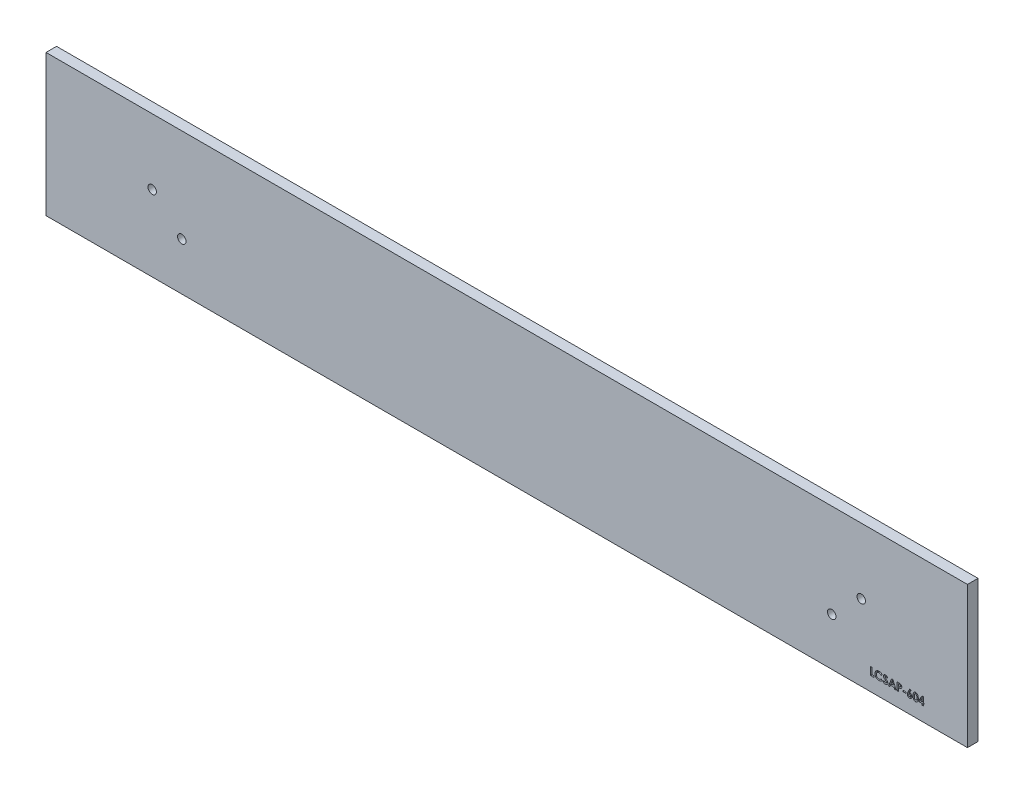
from build123d import *

# Parameters (mm, degrees)
SKETCH1_W           = 415.925
SKETCH1_H           = 63.8175
BOSS_EXTRUDE1_DEPTH = 4.7625
SKETCH2_R           = 1.905
CUT_EXTRUDE1_DEPTH  = 421.819391589
SKETCH3_W           = 1.211538462
SKETCH3_H           = 0.583333334
CUT_EXTRUDE2_DEPTH  = 1.016


with BuildPart() as part:
    # Sketch1 → Boss-Extrude1 (new body)
    with BuildSketch(Plane.XY):
        with Locations((207.9625, 31.90875)):
            Rectangle(SKETCH1_W, SKETCH1_H)
    extrude(amount=BOSS_EXTRUDE1_DEPTH)

    # Sketch2 → Cut-Extrude1 (cut, through all)
    with BuildSketch(Plane(origin=(0, 0, 0), x_dir=(-1, 0, 0), z_dir=(0, 0, -1))):
        with Locations((-367.9825, 34.2265)):
            Circle(SKETCH2_R)
        with Locations((-354.6475, 21.5265)):
            Circle(SKETCH2_R)
        with Locations((-47.9425, 34.2265)):
            Circle(SKETCH2_R)
        with Locations((-61.2775, 21.5265)):
            Circle(SKETCH2_R)
    extrude(amount=-CUT_EXTRUDE1_DEPTH, mode=Mode.SUBTRACT)

    # Sketch3 → Cut-Extrude2 (cut)
    # profile 1 of 9: a face of its own
    with BuildSketch(Plane.XY.offset(4.7625)):
        Polygon((395.456049679, 9.93974359), (396.110897436, 9.93974359), (396.110897436, 7.651282051), (396.425, 7.651282051), (396.425, 7.067948718), (396.110897436, 7.067948718), (396.110897436, 6.35), (395.482692308, 6.35), (395.482692308, 7.067948718), (394.001923077, 7.067948718), (394.001923077, 7.703866186), align=None)
        Polygon((395.482692308, 7.651282051), (395.482692308, 8.842487981), (394.707952724, 7.651282051), align=None, mode=Mode.SUBTRACT)
    # profile 2 of 9: a face of its own
    with BuildSketch(Plane.XY.offset(4.7625)):
        with BuildLine():
            add(Edge.make_bspline(
                [(392.533072917, 9.93974359), (392.563480652, 9.939292178), (392.623270385, 9.938404583), (392.711329406, 9.928791201), (392.796154591, 9.914268063), (392.878077785, 9.894013349), (392.956509297, 9.867206957), (393.032019968, 9.835120165), (393.103711003, 9.796069956), (393.172496691, 9.751960738), (393.238350535, 9.702022851), (393.299689786, 9.64509108), (393.357634627, 9.58247543), (393.410930767, 9.513229263), (393.460758465, 9.437982447), (393.506953994, 9.35672305), (393.549163718, 9.269053361), (393.587860706, 9.174815174), (393.622463675, 9.072595899), (393.651609713, 8.961223037), (393.676607317, 8.840671153), (393.697707059, 8.710640176), (393.713655053, 8.570957264), (393.724404323, 8.421715214), (393.73178098, 8.263201744), (393.732383012, 8.154462806), (393.732692308, 8.098597756)],
                knots=[0, 0, 0, 0, 0.879237366, 1.728815576, 2.559023295, 3.367336655, 4.166867292, 4.954216142, 5.737608147, 6.525189134, 7.316157332, 8.124696809, 8.942788509, 9.781158001, 10.649253743, 11.551476218, 12.482711956, 13.461909668, 14.496590415, 15.601789533, 16.789733467, 18.056700938, 19.410929216, 20.8549011, 22.384193279, 24, 24, 24, 24], degree=3))
            add(Edge.make_bspline(
                [(393.732692308, 8.098597756), (393.732358042, 8.042033772), (393.731708571, 7.932130965), (393.724710973, 7.77216765), (393.712660778, 7.621842014), (393.697129618, 7.481169608), (393.675856176, 7.350224719), (393.650942019, 7.228668289), (393.62133592, 7.116544378), (393.585593141, 7.014105625), (393.547130387, 6.919701935), (393.504805201, 6.832203181), (393.459355307, 6.751372369), (393.411823186, 6.675990055), (393.359602955, 6.608278471), (393.305236318, 6.545935071), (393.246356056, 6.491334593), (393.185441254, 6.441663175), (393.120260358, 6.398737102), (393.05148556, 6.361194666), (392.977890726, 6.330743291), (392.900817364, 6.304258312), (392.818951743, 6.285244955), (392.733594697, 6.27015848), (392.643782561, 6.261820769), (392.582634842, 6.260786421), (392.551302083, 6.26025641)],
                knots=[0, 0, 0, 0, 1.643780988, 3.193836972, 4.651895693, 6.025988579, 7.305620092, 8.505800249, 9.631074763, 10.672816429, 11.65661981, 12.592235626, 13.49536222, 14.350718032, 15.179365177, 15.97804903, 16.751647189, 17.51006938, 18.259804725, 19.016521909, 19.783502495, 20.571750527, 21.382245291, 22.22305063, 23.089471752, 24, 24, 24, 24], degree=3))
            add(Edge.make_bspline(
                [(392.551302083, 6.26025641), (392.51997017, 6.260796645), (392.458591414, 6.261854957), (392.368536417, 6.270096486), (392.282727022, 6.28530607), (392.200213712, 6.304404282), (392.121570768, 6.33068469), (392.0464211, 6.362047148), (391.975342543, 6.399355338), (391.908138292, 6.442381425), (391.845037802, 6.491720504), (391.78506049, 6.546844838), (391.728339031, 6.607614701), (391.675736299, 6.674710765), (391.626390812, 6.747237439), (391.580817167, 6.826022941), (391.539042751, 6.910952561), (391.499760854, 7.002144684), (391.465629858, 7.10156257), (391.435254856, 7.210094009), (391.410372454, 7.3286437), (391.39036036, 7.457173557), (391.374382717, 7.595411285), (391.362497186, 7.743423606), (391.35546072, 7.901279462), (391.354818059, 8.009781655), (391.354487179, 8.065645032)],
                knots=[0, 0, 0, 0, 0.917216111, 1.796812873, 2.643793957, 3.46689424, 4.273913431, 5.068098542, 5.848489301, 6.620921603, 7.401012384, 8.190319798, 9.003608147, 9.831726257, 10.68377682, 11.569763213, 12.493818149, 13.453288342, 14.474581811, 15.568529029, 16.750744269, 18.018426408, 19.375425659, 20.823733699, 22.36466933, 24, 24, 24, 24], degree=3))
            add(Edge.make_bspline(
                [(391.354487179, 8.065645032), (391.355086537, 8.143262797), (391.356243006, 8.293027275), (391.370898626, 8.509393402), (391.39240936, 8.709386406), (391.424003532, 8.892671749), (391.463069289, 9.059928265), (391.513095025, 9.210054156), (391.570045686, 9.345126752), (391.618574966, 9.425144571), (391.641947115, 9.463681891)],
                knots=[0, 0, 0, 0, 1.288568992, 2.486310467, 3.599230591, 4.627010532, 5.572937695, 6.447898582, 7.252493626, 8, 8, 8, 8], degree=3))
            add(Edge.make_bspline(
                [(391.641947115, 9.463681891), (391.669123137, 9.501540942), (391.722257615, 9.575562848), (391.815164735, 9.672739774), (391.914981339, 9.755850239), (392.023757603, 9.82301338), (392.139773185, 9.875978238), (392.264024139, 9.913386721), (392.396051626, 9.935182647), (392.486717103, 9.938200572), (392.533072917, 9.93974359)],
                knots=[0, 0, 0, 0, 1.058512271, 2.069600068, 3.047294572, 4.004278952, 4.967380941, 5.939006123, 6.946246673, 8, 8, 8, 8], degree=3))
        make_face()
        with BuildLine():
            add(Edge.make_bspline(
                [(392.548497596, 9.311538462), (392.521008751, 9.310235545), (392.467116023, 9.307681137), (392.388915106, 9.285997815), (392.315176524, 9.252506756), (392.259085555, 9.212205503), (392.217102022, 9.173571918), (392.187767826, 9.138609781), (392.159479618, 9.099594555), (392.134494048, 9.054765685), (392.110901148, 9.005733924), (392.087843773, 8.952276698), (392.06894278, 8.893080981), (392.050373055, 8.829154885), (392.034104244, 8.758731022), (392.020474546, 8.681233756), (392.00829761, 8.596159114), (391.999804052, 8.503451372), (391.991885506, 8.403207526), (391.986209118, 8.295204271), (391.983835962, 8.179470744), (391.983081608, 8.099766781), (391.982692308, 8.058633814)],
                knots=[0, 0, 0, 0, 1.076674018, 2.110852608, 3.161083442, 4.239746716, 4.804137807, 5.395870207, 6.026861976, 6.692161227, 7.405688833, 8.16177676, 8.973626916, 9.841385931, 10.773283133, 11.807421078, 12.927755683, 14.143907515, 15.458935494, 16.872852025, 18.386167141, 20, 20, 20, 20], degree=3))
            add(Edge.make_bspline(
                [(391.982692308, 8.058633814), (391.98333305, 8.005344067), (391.98456172, 7.903157026), (391.990996919, 7.756208503), (392.003895741, 7.622473515), (392.019939272, 7.501045689), (392.042473067, 7.392712518), (392.068399656, 7.29644907), (392.100416688, 7.21348247), (392.137418538, 7.142612834), (392.178399754, 7.082324181), (392.222886667, 7.031078555), (392.269364656, 6.986702261), (392.319284452, 6.950655944), (392.37252696, 6.923031708), (392.428647703, 6.903161936), (392.487682345, 6.890998822), (392.528108659, 6.889312189), (392.548497596, 6.888461538)],
                knots=[0, 0, 0, 0, 1.771748488, 3.397459088, 4.888034009, 6.237357457, 7.467047327, 8.564189669, 9.548206622, 10.417051504, 11.216568818, 11.965764335, 12.669334354, 13.348544111, 14.005342236, 14.656555988, 15.322436492, 16, 16, 16, 16], degree=3))
            add(Edge.make_bspline(
                [(392.548497596, 6.888461538), (392.56818685, 6.889043617), (392.606735959, 6.890183253), (392.662949195, 6.901881469), (392.716108425, 6.920900227), (392.766053145, 6.947803595), (392.812962, 6.982015344), (392.856605729, 7.023685815), (392.896655179, 7.073230366), (392.919988171, 7.109999749), (392.932011218, 7.128946314)],
                knots=[0, 0, 0, 0, 0.992283464, 1.942767638, 2.88273346, 3.832339453, 4.79467288, 5.803907806, 6.868395428, 8, 8, 8, 8], degree=3))
            add(Edge.make_bspline(
                [(392.932011218, 7.128946314), (392.946166331, 7.154836189), (392.975848455, 7.209125158), (393.010196661, 7.300735767), (393.039109066, 7.404057394), (393.06399355, 7.519411585), (393.081013019, 7.64725331), (393.095670165, 7.786771915), (393.102739671, 7.938669958), (393.103889565, 8.04390547), (393.104487179, 8.098597756)],
                knots=[0, 0, 0, 0, 0.710965849, 1.490837728, 2.352621235, 3.297892224, 4.334225155, 5.461620853, 6.680770821, 8, 8, 8, 8], degree=3))
            add(Edge.make_bspline(
                [(393.104487179, 8.098597756), (393.104256334, 8.153764798), (393.103811995, 8.259951935), (393.095659668, 8.412396063), (393.08430693, 8.551628473), (393.067701151, 8.677338316), (393.046334799, 8.789830761), (393.020000689, 8.889098454), (392.988954732, 8.975337033), (392.952137927, 9.048460505), (392.911361029, 9.110605426), (392.868075106, 9.163920947), (392.822097128, 9.209440394), (392.773503986, 9.247335064), (392.721170975, 9.276289435), (392.666097722, 9.296733616), (392.608171324, 9.309101659), (392.56865732, 9.310715231), (392.548497596, 9.311538462)],
                knots=[0, 0, 0, 0, 1.793836731, 3.452829483, 4.963243077, 6.335886805, 7.574563692, 8.684454726, 9.672768357, 10.54971625, 11.340229787, 12.085688095, 12.778991901, 13.440269426, 14.083255152, 14.715733572, 15.344777694, 16, 16, 16, 16], degree=3))
        make_face(mode=Mode.SUBTRACT)
    # profile 3 of 9: a face of its own
    with BuildSketch(Plane.XY.offset(4.7625)):
        with BuildLine():
            Line((389.904567308, 9.93974359), (390.460556891, 9.657892628))
            Line((390.460556891, 9.657892628), (389.850580929, 8.458974359))
            add(Edge.make_bspline(
                [(389.850580929, 8.458974359), (389.886617737, 8.458041348), (389.957598139, 8.456203629), (390.062031398, 8.441350882), (390.161871538, 8.415674043), (390.258125242, 8.381639463), (390.3496159, 8.335930683), (390.43781702, 8.281557705), (390.520446794, 8.21524401), (390.599399853, 8.141771954), (390.671191464, 8.060375475), (390.73355517, 7.972912373), (390.787904039, 7.881510636), (390.830152663, 7.784125384), (390.864231809, 7.68237089), (390.888821413, 7.575840396), (390.90285047, 7.464225415), (390.90478461, 7.388400302), (390.905769231, 7.349799679)],
                knots=[0, 0, 0, 0, 1.013260694, 1.995783107, 2.958651975, 3.908806537, 4.861209129, 5.829647963, 6.817170299, 7.835534541, 8.860094905, 9.863329007, 10.853101798, 11.844815043, 12.84250023, 13.867713965, 14.914507806, 16, 16, 16, 16], degree=3))
            add(Edge.make_bspline(
                [(390.905769231, 7.349799679), (390.90484656, 7.312591021), (390.903022834, 7.239045459), (390.887947329, 7.131025732), (390.863584522, 7.027387122), (390.828765177, 6.928336607), (390.784506974, 6.833390025), (390.73038219, 6.742603092), (390.665941964, 6.656654229), (390.592851255, 6.576000127), (390.5129505, 6.502483317), (390.428730752, 6.437137297), (390.339478345, 6.383159006), (390.246880252, 6.337573073), (390.149231686, 6.303556092), (390.047993963, 6.277879165), (389.942399368, 6.263062463), (389.870724462, 6.261199246), (389.834455128, 6.26025641)],
                knots=[0, 0, 0, 0, 1.049934834, 2.075270938, 3.072134561, 4.05064612, 5.033440221, 6.024524368, 7.028587226, 8.060776465, 9.092543989, 10.090062252, 11.064205434, 12.031961459, 12.998029633, 13.977230324, 14.976426867, 16, 16, 16, 16], degree=3))
            add(Edge.make_bspline(
                [(389.834455128, 6.26025641), (389.796528427, 6.261030145), (389.721950701, 6.26255159), (389.612824824, 6.279587767), (389.508163715, 6.305233356), (389.408555588, 6.3418509), (389.313381009, 6.388476396), (389.223760487, 6.446170758), (389.138939094, 6.514297771), (389.059821149, 6.591324685), (388.988541777, 6.675697131), (388.924966534, 6.763297697), (388.871181797, 6.854263848), (388.827644306, 6.948498322), (388.793675345, 7.045700839), (388.770039877, 7.14605588), (388.754639188, 7.249297254), (388.752833809, 7.319362693), (388.751923077, 7.354707532)],
                knots=[0, 0, 0, 0, 1.063775006, 2.091769615, 3.092589432, 4.084662827, 5.064601646, 6.061867366, 7.070035304, 8.113879863, 9.156342271, 10.166834137, 11.149076039, 12.117706134, 13.076241869, 14.034148791, 15.008317125, 16, 16, 16, 16], degree=3))
            add(Edge.make_bspline(
                [(388.751923077, 7.354707532), (388.75240429, 7.382077976), (388.753369394, 7.436971218), (388.763068118, 7.519170865), (388.777813586, 7.601586278), (388.794905513, 7.671131014), (388.812505052, 7.729938366), (388.830219124, 7.779705439), (388.852171813, 7.834936007), (388.877266989, 7.895771109), (388.906293802, 7.962137558), (388.939100623, 8.033854458), (388.975769126, 8.111464902), (389.001918819, 8.16477126), (389.015544872, 8.192548077)],
                knots=[0, 0, 0, 0, 1.110454016, 2.227089276, 3.35462975, 4.507227546, 5.131400587, 5.845402449, 6.650387134, 7.543487832, 8.516250726, 9.590168902, 10.744287919, 12, 12, 12, 12], degree=3))
            Line((389.015544872, 8.192548077), (389.904567308, 9.93974359))
        make_face()
        with BuildLine():
            add(Edge.make_bspline(
                [(389.820432692, 7.875641026), (389.790289498, 7.874258421), (389.731303224, 7.871552845), (389.647433564, 7.843218739), (389.570963463, 7.798769578), (389.504678234, 7.736865525), (389.449236738, 7.662887751), (389.408496382, 7.578506218), (389.383988794, 7.484846975), (389.381442612, 7.419361994), (389.380128205, 7.385556891)],
                knots=[0, 0, 0, 0, 0.981744412, 1.921144944, 2.858899012, 3.85339082, 4.86292663, 5.863643845, 6.897155691, 8, 8, 8, 8], degree=3))
            add(Edge.make_bspline(
                [(389.380128205, 7.385556891), (389.381684504, 7.351740531), (389.38471161, 7.285965451), (389.410140716, 7.191414405), (389.451776052, 7.105116665), (389.510166957, 7.030158525), (389.578717039, 6.967937465), (389.65473095, 6.921922016), (389.73694075, 6.893653216), (389.793807276, 6.890204047), (389.822536058, 6.888461538)],
                knots=[0, 0, 0, 0, 1.098279937, 2.136227893, 3.159405121, 4.194678092, 5.206500211, 6.154139736, 7.067477469, 8, 8, 8, 8], degree=3))
            add(Edge.make_bspline(
                [(389.822536058, 6.888461538), (389.852876898, 6.890235082), (389.912380557, 6.89371331), (389.998218487, 6.920792611), (390.076631951, 6.96603715), (390.14596462, 7.028059004), (390.205520066, 7.102161771), (390.246726419, 7.188966412), (390.273331124, 7.284199894), (390.276121474, 7.351013724), (390.277564103, 7.385556891)],
                knots=[0, 0, 0, 0, 0.96921794, 1.900804717, 2.848419905, 3.844199796, 4.861108892, 5.867439427, 6.897452859, 8, 8, 8, 8], degree=3))
            add(Edge.make_bspline(
                [(390.277564103, 7.385556891), (390.275920685, 7.419342255), (390.272738015, 7.484771558), (390.248832395, 7.578869573), (390.206150523, 7.662925868), (390.149454619, 7.737170894), (390.080888204, 7.799047343), (390.001357614, 7.843569279), (389.913656648, 7.871502646), (389.851960415, 7.874241453), (389.820432692, 7.875641026)],
                knots=[0, 0, 0, 0, 1.083229974, 2.097801324, 3.086792542, 4.086858909, 5.079819718, 6.026392613, 6.991456328, 8, 8, 8, 8], degree=3))
        make_face(mode=Mode.SUBTRACT)
    # profile 4 of 9: a face of its own
    with BuildSketch(Plane.XY.offset(4.7625)):
        with Locations((387.517948718, 7.628846154)):
            Rectangle(SKETCH3_W, SKETCH3_H)
    # profile 5 of 9: a face of its own
    with BuildSketch(Plane.XY.offset(4.7625)):
        with BuildLine():
            Line((384.219871795, 9.85), (384.92099359, 9.85))
            add(Edge.make_bspline(
                [(384.92099359, 9.85), (384.966803978, 9.849794943), (385.05518182, 9.849399345), (385.182629939, 9.844602193), (385.30020707, 9.836005403), (385.407886197, 9.825381131), (385.505623048, 9.810486316), (385.593540018, 9.793410575), (385.671655351, 9.772607354), (385.740849914, 9.747914219), (385.802949799, 9.718801977), (385.86171632, 9.687795361), (385.915821346, 9.650790059), (385.967995721, 9.611774345), (386.015256547, 9.567021062), (386.060552237, 9.519508606), (386.101964394, 9.467352673), (386.139684908, 9.411184597), (386.173903226, 9.352042122), (386.203798638, 9.28981952), (386.228048122, 9.22441833), (386.248390424, 9.156261623), (386.264729559, 9.085352371), (386.275605407, 9.011254473), (386.28299283, 8.934485311), (386.283644668, 8.882236171), (386.283974359, 8.855809295)],
                knots=[0, 0, 0, 0, 1.698747864, 3.27724071, 4.728299578, 6.070144658, 7.288476769, 8.393259625, 9.389771311, 10.283485332, 11.113357557, 11.931608583, 12.74405601, 13.541433047, 14.344816069, 15.154114104, 15.974336324, 16.810834471, 17.661136416, 18.50621059, 19.367396281, 20.244825668, 21.142564693, 22.063065223, 23.020325768, 24, 24, 24, 24], degree=3))
            add(Edge.make_bspline(
                [(386.283974359, 8.855809295), (386.283497338, 8.826573871), (386.282559933, 8.769122669), (386.273370347, 8.684906257), (386.25767163, 8.604613532), (386.237154229, 8.527567372), (386.208544171, 8.455035358), (386.175858523, 8.385286853), (386.13564481, 8.320277391), (386.089694213, 8.259193782), (386.039510919, 8.201539387), (385.983903578, 8.148978868), (385.923932091, 8.101153923), (385.859943611, 8.057563341), (385.791697906, 8.018295054), (385.719244218, 7.982981357), (385.642087793, 7.952751692), (385.58835838, 7.936941821), (385.561117788, 7.928926282)],
                knots=[0, 0, 0, 0, 1.102006807, 2.165578795, 3.188629044, 4.184801286, 5.166646146, 6.124351954, 7.085497154, 8.042432466, 9.003981491, 9.963833307, 10.922997304, 11.89326795, 12.880200226, 13.889073926, 14.929769137, 16, 16, 16, 16], degree=3))
            add(Edge.make_bspline(
                [(385.561117788, 7.928926282), (385.543175568, 7.924462228), (385.504306939, 7.914791651), (385.439990035, 7.904973587), (385.365871557, 7.895946482), (385.28171183, 7.888188777), (385.187462334, 7.882915346), (385.083214328, 7.87879703), (384.968920568, 7.87580259), (384.889445207, 7.875696334), (384.848076923, 7.875641026)],
                knots=[0, 0, 0, 0, 0.618981996, 1.340914327, 2.176866532, 3.120127938, 4.170906482, 5.338178032, 6.614476169, 8, 8, 8, 8], degree=3))
            Line((384.848076923, 7.875641026), (384.848076923, 6.35))
            Line((384.848076923, 6.35), (384.219871795, 6.35))
            Line((384.219871795, 6.35), (384.219871795, 9.85))
        make_face()
        with BuildLine():
            Line((384.848076923, 8.503846154), (385.070332532, 8.503846154))
            add(Edge.make_bspline(
                [(385.070332532, 8.503846154), (385.110775449, 8.504102593), (385.185191017, 8.504574446), (385.286816404, 8.511397707), (385.368484521, 8.521818204), (385.433003849, 8.536763608), (385.48394797, 8.559445236), (385.527884084, 8.585683609), (385.565569212, 8.618861312), (385.598198985, 8.656772514), (385.624285506, 8.700334385), (385.642375149, 8.748837605), (385.654125826, 8.801263069), (385.65521111, 8.837747722), (385.655769231, 8.856510417)],
                knots=[0, 0, 0, 0, 1.8619151, 3.425951444, 4.686033666, 5.651700536, 6.461346321, 7.243864085, 7.999046032, 8.762387399, 9.539336099, 10.322741239, 11.137448474, 12, 12, 12, 12], degree=3))
            add(Edge.make_bspline(
                [(385.655769231, 8.856510417), (385.655216851, 8.872903138), (385.654145101, 8.904708959), (385.646271733, 8.950612649), (385.633723849, 8.993404356), (385.615542447, 9.03263718), (385.592038201, 9.068244457), (385.563381767, 9.100212159), (385.529940866, 9.129224904), (385.504122535, 9.144581793), (385.491005609, 9.152383814)],
                knots=[0, 0, 0, 0, 1.102301479, 2.1387299, 3.123554645, 4.094223062, 5.036071848, 5.982632524, 6.975082478, 8, 8, 8, 8], degree=3))
            add(Edge.make_bspline(
                [(385.491005609, 9.152383814), (385.479894815, 9.158002861), (385.456370989, 9.169899535), (385.416307631, 9.183730288), (385.370075129, 9.195398051), (385.317361359, 9.205082183), (385.258376613, 9.212598074), (385.193131415, 9.218345851), (385.121529749, 9.220657256), (385.071735075, 9.221405207), (385.045793269, 9.221794872)],
                knots=[0, 0, 0, 0, 0.656809284, 1.390599849, 2.23162475, 3.173112763, 4.218524733, 5.370385145, 6.63003504, 8, 8, 8, 8], degree=3))
            Line((385.045793269, 9.221794872), (384.848076923, 9.221794872))
            Line((384.848076923, 9.221794872), (384.848076923, 8.503846154))
        make_face(mode=Mode.SUBTRACT)
    # profile 6 of 9: a face of its own
    with BuildSketch(Plane.XY.offset(4.7625)):
        Polygon((381.707752404, 9.85), (382.290384615, 9.85), (383.703846154, 6.35), (383.032872596, 6.35), (382.76083734, 7.067948718), (381.235897436, 7.067948718), (380.963862179, 6.35), (380.293589744, 6.35), align=None)
        Polygon((381.998717949, 8.911197917), (381.474278846, 7.696153846), (382.523157051, 7.696153846), align=None, mode=Mode.SUBTRACT)
    # profile 7 of 9: a face of its own
    with BuildSketch(Plane.XY.offset(4.7625)):
        with BuildLine():
            Line((379.912179487, 9.382351763), (379.442427885, 8.952564103))
            add(Edge.make_bspline(
                [(379.442427885, 8.952564103), (379.42230574, 8.980948479), (379.383674029, 9.035442524), (379.321056055, 9.108411334), (379.258720833, 9.17065916), (379.196090865, 9.221925958), (379.132611023, 9.261900244), (379.0683915, 9.290202481), (379.003796372, 9.308194481), (378.960398418, 9.310434918), (378.939022436, 9.311538462)],
                knots=[0, 0, 0, 0, 1.299362458, 2.494594718, 3.587462134, 4.587049575, 5.512617175, 6.380583204, 7.202344345, 8, 8, 8, 8], degree=3))
            add(Edge.make_bspline(
                [(378.939022436, 9.311538462), (378.919083533, 9.310839206), (378.880586751, 9.309489126), (378.825706732, 9.296069437), (378.776983469, 9.272909025), (378.734464515, 9.242624837), (378.70078323, 9.206139412), (378.673891336, 9.167875583), (378.65874894, 9.125640968), (378.656755902, 9.096632532), (378.655769231, 9.082271635)],
                knots=[0, 0, 0, 0, 1.185010067, 2.2879431, 3.333075148, 4.379039566, 5.372662701, 6.27520591, 7.14612461, 8, 8, 8, 8], degree=3))
            add(Edge.make_bspline(
                [(378.655769231, 9.082271635), (378.656387528, 9.067703647), (378.657632692, 9.038365745), (378.669659286, 8.995367395), (378.687786797, 8.953353002), (378.705108374, 8.927776842), (378.71396234, 8.914703526)],
                knots=[0, 0, 0, 0, 0.967525499, 1.948461899, 2.951351359, 4, 4, 4, 4], degree=3))
            add(Edge.make_bspline(
                [(378.71396234, 8.914703526), (378.722011552, 8.904541774), (378.740539777, 8.881150764), (378.775869306, 8.84410305), (378.820235775, 8.798716357), (378.875346498, 8.746551401), (378.938913679, 8.685732126), (379.013883738, 8.618649361), (379.098098709, 8.543225631), (379.15795676, 8.490703276), (379.189322917, 8.46318109)],
                knots=[0, 0, 0, 0, 0.473873513, 1.090794244, 1.870441696, 2.795289791, 3.865433203, 5.087734844, 6.473946851, 8, 8, 8, 8], degree=3))
            add(Edge.make_bspline(
                [(379.189322917, 8.46318109), (379.218764567, 8.437700826), (379.274638703, 8.38934458), (379.354136503, 8.320710653), (379.424001829, 8.258962381), (379.485252459, 8.205026476), (379.536959893, 8.158337026), (379.579341511, 8.118670855), (379.612914931, 8.086800191), (379.631999454, 8.067550291), (379.640144231, 8.059334936)],
                knots=[0, 0, 0, 0, 1.543621617, 2.929473131, 4.163658386, 5.240097082, 6.164993805, 6.925417477, 7.541396219, 8, 8, 8, 8], degree=3))
            add(Edge.make_bspline(
                [(379.640144231, 8.059334936), (379.671043815, 8.025894968), (379.730443668, 7.961611605), (379.807642537, 7.861992611), (379.871179703, 7.764744159), (379.92033326, 7.668036363), (379.957456003, 7.570473922), (379.983628028, 7.469664122), (379.999302628, 7.364553564), (380.001042875, 7.292828439), (380.001923077, 7.256550481)],
                knots=[0, 0, 0, 0, 1.206664779, 2.319633467, 3.337109185, 4.282041471, 5.190008762, 6.099243693, 7.03861361, 8, 8, 8, 8], degree=3))
            add(Edge.make_bspline(
                [(380.001923077, 7.256550481), (380.001296572, 7.221202059), (380.000067345, 7.151847141), (379.985011678, 7.050356549), (379.963543179, 6.953225647), (379.930349114, 6.861511358), (379.889892385, 6.773708218), (379.839174031, 6.691183923), (379.779612279, 6.613103292), (379.711345367, 6.540862112), (379.635834055, 6.475308248), (379.554840996, 6.41695065), (379.4675742, 6.36876902), (379.37477926, 6.329094884), (379.276505848, 6.298537334), (379.172871036, 6.275952457), (379.063716308, 6.262397369), (378.989074733, 6.260980346), (378.950941506, 6.26025641)],
                knots=[0, 0, 0, 0, 1.043214005, 2.046824704, 3.02475056, 3.976699089, 4.921714032, 5.875962561, 6.831408892, 7.817874052, 8.806269674, 9.781291748, 10.760897367, 11.74438705, 12.757449933, 13.795994037, 14.874007457, 16, 16, 16, 16], degree=3))
            add(Edge.make_bspline(
                [(378.950941506, 6.26025641), (378.921007249, 6.260787464), (378.861720251, 6.261839255), (378.774340179, 6.270426251), (378.689964843, 6.284284751), (378.608689282, 6.30414812), (378.530147336, 6.329317702), (378.45433578, 6.360061383), (378.381777966, 6.396855678), (378.311924887, 6.43894395), (378.245116116, 6.487813977), (378.180506881, 6.542466629), (378.118738943, 6.603742487), (378.059515643, 6.671496636), (378.003215908, 6.74592094), (377.947996846, 6.825978902), (377.896312559, 6.91315629), (377.864384875, 6.974311933), (377.848076923, 7.005548878)],
                knots=[0, 0, 0, 0, 1.016823716, 2.013894106, 2.979844003, 3.91962641, 4.853723003, 5.779685073, 6.695824784, 7.614987388, 8.547259901, 9.504950863, 10.487499108, 11.500346958, 12.559593716, 13.656357062, 14.802919212, 16, 16, 16, 16], degree=3))
            Line((377.848076923, 7.005548878), (378.400560897, 7.337179487))
            add(Edge.make_bspline(
                [(378.400560897, 7.337179487), (378.420959708, 7.301721473), (378.460065971, 7.23374543), (378.526335191, 7.142411001), (378.594224623, 7.064198182), (378.66530381, 7.000489388), (378.738708457, 6.950432751), (378.814793124, 6.914658806), (378.893611268, 6.892514774), (378.947298607, 6.889810476), (378.974078526, 6.888461538)],
                knots=[0, 0, 0, 0, 1.283663364, 2.460892379, 3.537111102, 4.529833553, 5.449777664, 6.316464042, 7.160231139, 8, 8, 8, 8], degree=3))
            add(Edge.make_bspline(
                [(378.974078526, 6.888461538), (379.001317537, 6.889563154), (379.054165185, 6.891700449), (379.12959844, 6.911441996), (379.198758505, 6.942437673), (379.258539954, 6.98666423), (379.309159116, 7.037708399), (379.346518963, 7.094497371), (379.369988671, 7.155941668), (379.372469988, 7.198624918), (379.373717949, 7.220092147)],
                knots=[0, 0, 0, 0, 1.13588714, 2.203786484, 3.234766741, 4.283437687, 5.291419208, 6.222934724, 7.106237994, 8, 8, 8, 8], degree=3))
            add(Edge.make_bspline(
                [(379.373717949, 7.220092147), (379.372565508, 7.240063911), (379.370224436, 7.280634636), (379.35298082, 7.34095678), (379.326023789, 7.401251492), (379.294131721, 7.450706845), (379.261677547, 7.492114472), (379.230644037, 7.527992307), (379.192853432, 7.567631034), (379.148401551, 7.611080516), (379.09787572, 7.658723248), (379.041233377, 7.710554566), (378.977825908, 7.766117898), (378.933009383, 7.80396709), (378.909575321, 7.823758013)],
                knots=[0, 0, 0, 0, 0.916159276, 1.861089862, 2.860218735, 3.940849679, 4.552606315, 5.27541173, 6.11797699, 7.06649574, 8.129236253, 9.306560635, 10.591630461, 12, 12, 12, 12], degree=3))
            add(Edge.make_bspline(
                [(378.909575321, 7.823758013), (378.865026234, 7.861450812), (378.779523053, 7.933794702), (378.658696211, 8.04064435), (378.549820407, 8.140505137), (378.453836011, 8.23461156), (378.369520031, 8.321225691), (378.297443494, 8.401051045), (378.238398192, 8.474703364), (378.176265743, 8.561939606), (378.117227494, 8.668242962), (378.066201694, 8.796138223), (378.033098308, 8.924017255), (378.029389534, 9.009868194), (378.027564103, 9.052123397)],
                knots=[0, 0, 0, 0, 1.345494975, 2.582412109, 3.71882943, 4.751509156, 5.681369928, 6.505683931, 7.230279997, 7.856715994, 8.973648664, 10.023341002, 11.027102913, 12, 12, 12, 12], degree=3))
            add(Edge.make_bspline(
                [(378.027564103, 9.052123397), (378.028323297, 9.08208852), (378.029818992, 9.14112303), (378.043160819, 9.227924675), (378.063100688, 9.311680969), (378.092059103, 9.392086331), (378.129643629, 9.469040051), (378.175288575, 9.542918848), (378.229702722, 9.613042759), (378.291023792, 9.679365297), (378.358583912, 9.739976549), (378.430780485, 9.793472052), (378.507204873, 9.838655132), (378.58738955, 9.876137778), (378.671831387, 9.904828362), (378.759908306, 9.925165678), (378.851746635, 9.937261665), (378.914213085, 9.938905974), (378.946033654, 9.93974359)],
                knots=[0, 0, 0, 0, 1.010766082, 1.991317756, 2.957454644, 3.913069143, 4.869106762, 5.843196583, 6.838735724, 7.860187025, 8.887984031, 9.89767229, 10.887916223, 11.879572884, 12.879850636, 13.892031539, 14.926195476, 16, 16, 16, 16], degree=3))
            add(Edge.make_bspline(
                [(378.946033654, 9.93974359), (378.987271536, 9.93823502), (379.069421784, 9.935229789), (379.190883295, 9.911729864), (379.309521821, 9.874773756), (379.405122968, 9.830190278), (379.481191016, 9.787002242), (379.539490069, 9.747240139), (379.598812494, 9.701690512), (379.659636689, 9.650209824), (379.720832446, 9.59182811), (379.784139854, 9.527935192), (379.848696271, 9.457978887), (379.890647706, 9.408002427), (379.912179487, 9.382351763)],
                knots=[0, 0, 0, 0, 1.282922637, 2.555718331, 3.837320111, 5.142675274, 5.830281639, 6.55870424, 7.337177975, 8.157850921, 9.037902056, 9.96903443, 10.957596896, 12, 12, 12, 12], degree=3))
        make_face()
    # profile 8 of 9: a face of its own
    with BuildSketch(Plane.XY.offset(4.7625)):
        with BuildLine():
            Line((377.489102564, 9.242828526), (377.028465545, 8.802524038))
            add(Edge.make_bspline(
                [(377.028465545, 8.802524038), (376.98939056, 8.842927638), (376.913064873, 8.921848526), (376.790075468, 9.026332827), (376.662170965, 9.113406355), (376.531839491, 9.186739125), (376.39673676, 9.242220593), (376.258424927, 9.282650872), (376.116020832, 9.307299686), (376.019647218, 9.310119946), (375.971173878, 9.311538462)],
                knots=[0, 0, 0, 0, 1.115251505, 2.178435587, 3.19620269, 4.182487026, 5.141301733, 6.088180966, 7.038406374, 8, 8, 8, 8], degree=3))
            add(Edge.make_bspline(
                [(375.971173878, 9.311538462), (375.930692749, 9.310417785), (375.850807701, 9.308206253), (375.733515516, 9.291993543), (375.621319479, 9.264423124), (375.513835526, 9.226425979), (375.411379932, 9.17725969), (375.313737887, 9.116962311), (375.221150123, 9.046078413), (375.134839671, 8.964974752), (375.055885903, 8.876362907), (374.986125222, 8.781814281), (374.927689461, 8.681545478), (374.879732182, 8.576571947), (374.842375316, 8.466407818), (374.81569782, 8.35112726), (374.80026827, 8.23059298), (374.797965306, 8.148654675), (374.796794872, 8.107011218)],
                knots=[0, 0, 0, 0, 1.035432265, 2.043311493, 3.022114605, 3.98653278, 4.95457646, 5.923598177, 6.917315552, 7.932509744, 8.948865224, 9.949768934, 10.933144597, 11.912367597, 12.897413939, 13.903909035, 14.934704909, 16, 16, 16, 16], degree=3))
            add(Edge.make_bspline(
                [(374.796794872, 8.107011218), (374.797132178, 8.077782926), (374.797797014, 8.020173362), (374.805074825, 7.934952828), (374.816793818, 7.852268764), (374.833754103, 7.772246412), (374.854963107, 7.694816425), (374.879846097, 7.61931082), (374.911061442, 7.546772912), (374.945710947, 7.476360221), (374.986007921, 7.409994047), (375.029455493, 7.346708391), (375.076567292, 7.286813475), (375.127648463, 7.23055415), (375.183417909, 7.178809624), (375.242434199, 7.130023877), (375.305692853, 7.085418182), (375.37187983, 7.04387311), (375.441566902, 7.007782552), (375.512863297, 6.975091479), (375.586850012, 6.948541467), (375.662626214, 6.927139735), (375.739921105, 6.908940759), (375.819490703, 6.89773509), (375.900645237, 6.889249168), (375.95549208, 6.888725212), (375.983092949, 6.888461538)],
                knots=[0, 0, 0, 0, 1.103660481, 2.175337485, 3.227646561, 4.255952547, 5.262355991, 6.258840057, 7.255597736, 8.242457506, 9.22035537, 10.185017736, 11.140346927, 12.096287581, 13.051739095, 14.01125915, 14.986044842, 15.97314143, 16.960198552, 17.947847494, 18.933482797, 19.925264591, 20.920966487, 21.929612487, 22.958107872, 24, 24, 24, 24], degree=3))
            add(Edge.make_bspline(
                [(375.983092949, 6.888461538), (376.029908766, 6.8898157), (376.121889672, 6.892476276), (376.256884878, 6.913281603), (376.38552186, 6.947505189), (376.488302193, 6.987921255), (376.568827869, 7.027832645), (376.630130876, 7.064748715), (376.693522963, 7.106043392), (376.757951242, 7.153275183), (376.824140403, 7.205877287), (376.890922055, 7.265001788), (376.96000582, 7.328701801), (377.00526191, 7.374165752), (377.028465545, 7.397475962)],
                knots=[0, 0, 0, 0, 1.404581149, 2.759636711, 4.088442092, 5.392261763, 6.066678138, 6.783632037, 7.538459478, 8.336747902, 9.180226004, 10.074962426, 11.012997595, 12, 12, 12, 12], degree=3))
            Line((377.028465545, 7.397475962), (377.475080128, 6.928425481))
            add(Edge.make_bspline(
                [(377.475080128, 6.928425481), (377.443685527, 6.898114979), (377.382409979, 6.838955361), (377.289977517, 6.754954225), (377.197661384, 6.679469865), (377.107691746, 6.609762532), (377.018594808, 6.547862968), (376.930380017, 6.493709355), (376.844046003, 6.445932068), (376.757800013, 6.405336849), (376.671105381, 6.370867291), (376.581906792, 6.341191265), (376.489931558, 6.316086414), (376.394617936, 6.295830096), (376.296854954, 6.279587264), (376.195727681, 6.268623446), (376.091877313, 6.261252837), (376.021433999, 6.260590526), (375.985897436, 6.26025641)],
                knots=[0, 0, 0, 0, 1.244526981, 2.429050516, 3.560637417, 4.644440555, 5.67424972, 6.652764056, 7.595344123, 8.486817594, 9.369275933, 10.254498637, 11.166417451, 12.086725134, 13.032340136, 13.991389299, 14.986715468, 16, 16, 16, 16], degree=3))
            add(Edge.make_bspline(
                [(375.985897436, 6.26025641), (375.920621172, 6.261920432), (375.792893668, 6.265176461), (375.605712341, 6.28930143), (375.427895106, 6.329746515), (375.259009365, 6.386947022), (375.09910882, 6.460017988), (374.94823438, 6.549599561), (374.80662922, 6.655453737), (374.675437231, 6.776339803), (374.556767833, 6.909848314), (374.451877828, 7.053199828), (374.365112812, 7.207098866), (374.29306995, 7.369271846), (374.236733379, 7.540458828), (374.197081983, 7.720844982), (374.172629257, 7.910256136), (374.169954094, 8.039628321), (374.168589744, 8.105608974)],
                knots=[0, 0, 0, 0, 1.078019885, 2.10938526, 3.111377082, 4.085535484, 5.04941344, 6.010039228, 6.978205633, 7.964457913, 8.951525778, 9.924444315, 10.892603023, 11.863865945, 12.85144698, 13.863884204, 14.910567087, 16, 16, 16, 16], degree=3))
            add(Edge.make_bspline(
                [(374.168589744, 8.105608974), (374.169166252, 8.148640994), (374.170308751, 8.233919938), (374.182316518, 8.359542733), (374.199056044, 8.482002487), (374.22561178, 8.600027663), (374.2576221, 8.715208277), (374.297431139, 8.826292451), (374.344975316, 8.933599451), (374.398722171, 9.037308917), (374.459525449, 9.13674144), (374.527449387, 9.231042737), (374.600745355, 9.320940799), (374.681174538, 9.405242959), (374.767568194, 9.484689407), (374.860316381, 9.558849608), (374.958861263, 9.628787103), (375.063469567, 9.692698373), (375.17210903, 9.750509514), (375.283409424, 9.801501409), (375.397097296, 9.844118891), (375.512691964, 9.879468521), (375.630681814, 9.905854519), (375.750224664, 9.925827869), (375.87233768, 9.936993099), (375.954325991, 9.938820919), (375.995713141, 9.93974359)],
                knots=[0, 0, 0, 0, 1.071919942, 2.124283339, 3.142214191, 4.149696895, 5.136002878, 6.119640489, 7.086990633, 8.058538607, 9.028339693, 9.988281803, 10.952401235, 11.916291999, 12.888973767, 13.874849856, 14.873389453, 15.898127285, 16.927174885, 17.938320013, 18.946391617, 19.950418109, 20.947802303, 21.956882652, 22.968648068, 24, 24, 24, 24], degree=3))
            add(Edge.make_bspline(
                [(375.995713141, 9.93974359), (376.031020623, 9.939214692), (376.101268488, 9.938162395), (376.205879347, 9.929390354), (376.309653577, 9.915613953), (376.412219636, 9.894828298), (376.514311179, 9.870153099), (376.614586609, 9.837844329), (376.714627827, 9.801830117), (376.812865834, 9.758782479), (376.909437755, 9.711792095), (377.002081242, 9.658479797), (377.09235177, 9.602126365), (377.178248999, 9.539396556), (377.261381968, 9.472565697), (377.341315967, 9.401321984), (377.41734953, 9.324477576), (377.465063972, 9.270182466), (377.489102564, 9.242828526)],
                knots=[0, 0, 0, 0, 0.996412454, 1.982464992, 2.961075852, 3.949442424, 4.934965278, 5.923860011, 6.921385422, 7.934793307, 8.949617135, 9.951082467, 10.950285876, 11.951772932, 12.951063433, 13.960125323, 14.972308753, 16, 16, 16, 16], degree=3))
        make_face()
    # profile 9 of 9: a face of its own
    with BuildSketch(Plane.XY.offset(4.7625)):
        Polygon((372.194230769, 9.85), (372.822435897, 9.85), (372.822435897, 6.978205128), (373.809615385, 6.978205128), (373.809615385, 6.35), (372.194230769, 6.35), align=None)
    extrude(amount=-CUT_EXTRUDE2_DEPTH, mode=Mode.SUBTRACT)


solid = part.part
